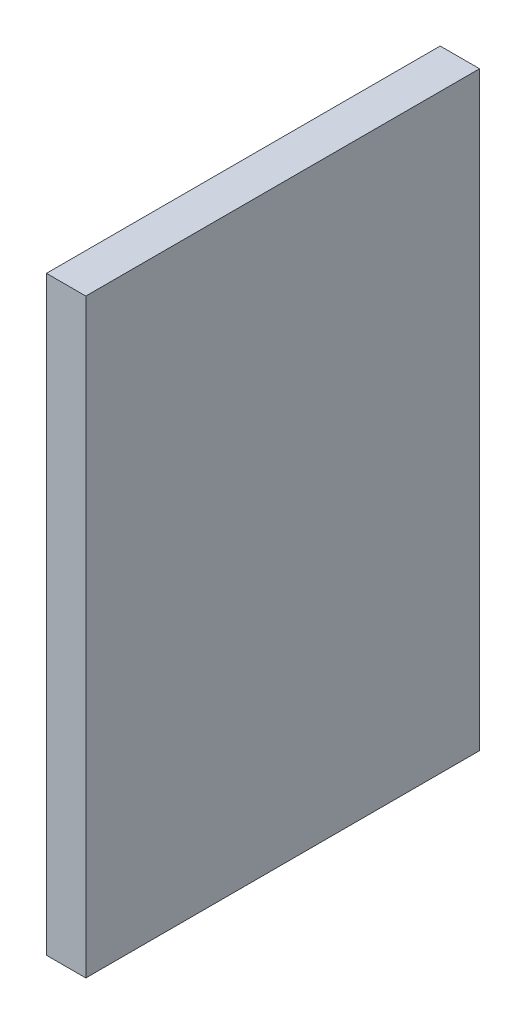
from build123d import *

# Parameters (mm, degrees)
SKETCH1_W           = 100
SKETCH1_H           = 150
BOSS_EXTRUDE1_DEPTH = 10


with BuildPart() as part:
    # Sketch1 → Boss-Extrude1 (new body)
    with BuildSketch(Plane(origin=(0, 0, 0), x_dir=(0, 0, -1), z_dir=(1, 0, 0))):
        Rectangle(SKETCH1_W, SKETCH1_H)
    extrude(amount=BOSS_EXTRUDE1_DEPTH)


solid = part.part
